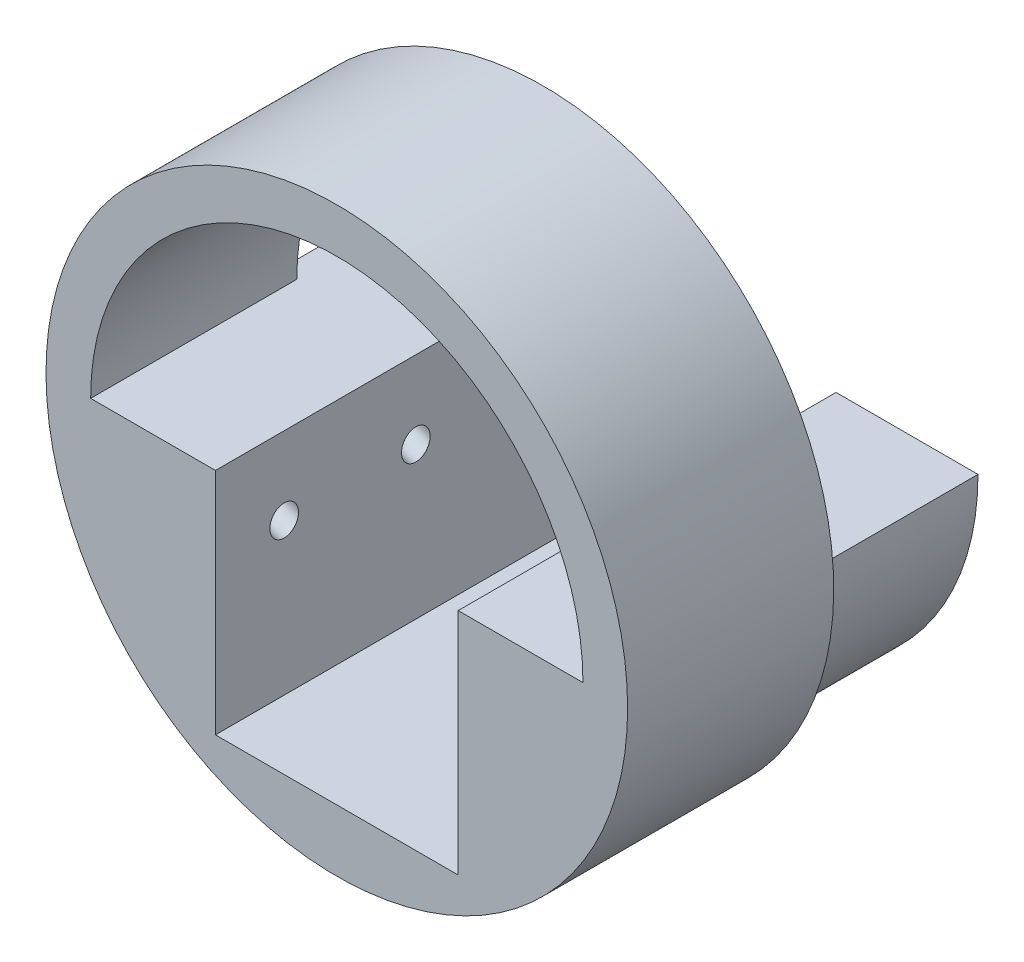
from build123d import *

# Parameters (mm, degrees)
SKETCH1_R                       = 25.4
BOSS_EXTRUDE1_DEPTH             = 33
CUT_EXTRUDE1_DEPTH              = 34
SKETCH3_R                       = 25.4
SKETCH3_R_2                     = 23
CUT_EXTRUDE2_DEPTH              = 15
M3X0_5_TAPPED_HOLE1_D           = 2.5
M3X0_5_TAPPED_HOLE1_DEPTH       = 25
M3X0_5_TAPPED_HOLE1_CSINK_D     = 3.05
M3X0_5_TAPPED_HOLE1_CSINK_ANGLE = 90
M3X0_5_TAPPED_HOLE1_TIP         = 0.751075774
SKETCH6_W                       = 55.513598287
SKETCH6_H                       = 26.495126455
CUT_EXTRUDE3_DEPTH              = 15


with BuildPart() as part:
    # Sketch1 → Boss-Extrude1 (new body)
    with BuildSketch(Plane.XY):
        Circle(SKETCH1_R)
    extrude(amount=BOSS_EXTRUDE1_DEPTH)

    # Sketch2 → Cut-Extrude1 (cut, through all)
    with BuildSketch(Plane.XY.offset(33)):
        with BuildLine():
            Line((-21.5, 0), (-10.6, 0))
            Line((-10.6, 0), (-10.6, -20))
            Line((-10.6, -20), (10.6, -20))
            Line((10.6, -20), (10.6, 0))
            Line((10.6, 0), (21.5, 0))
            ThreePointArc((21.5, 0), (0, 21.5), (-21.5, 0))
        make_face()
    extrude(amount=-CUT_EXTRUDE1_DEPTH, mode=Mode.SUBTRACT)

    # Sketch3 → Cut-Extrude2 (cut)
    with BuildSketch(Plane(origin=(0, 0, 0), x_dir=(-1, 0, 0), z_dir=(0, 0, -1))):
        Circle(SKETCH3_R)
        Circle(SKETCH3_R_2, mode=Mode.SUBTRACT)
    extrude(amount=-CUT_EXTRUDE2_DEPTH, mode=Mode.SUBTRACT)

    # M3x0.5 Tapped Hole1
    with Locations(Plane(origin=(-23.868192568, 8.68731164, 0), x_dir=(0, 0, -1), z_dir=(-0.939692621, 0.342020143, 0))):
        with Locations((-27, 10), (-15.5, 10), (-6, 10)):
            CounterSinkHole(M3X0_5_TAPPED_HOLE1_D / 2, M3X0_5_TAPPED_HOLE1_CSINK_D / 2, depth=M3X0_5_TAPPED_HOLE1_DEPTH, counter_sink_angle=M3X0_5_TAPPED_HOLE1_CSINK_ANGLE)
            with Locations((0, 0, -(M3X0_5_TAPPED_HOLE1_DEPTH + M3X0_5_TAPPED_HOLE1_TIP / 2))):  # 118° drill point
                Cone(0, M3X0_5_TAPPED_HOLE1_D / 2, M3X0_5_TAPPED_HOLE1_TIP, mode=Mode.SUBTRACT)

    # Sketch6 → Cut-Extrude3 (cut)
    with BuildSketch(Plane(origin=(0, 0, 0), x_dir=(-1, 0, 0), z_dir=(0, 0, -1))):
        with Locations((1.479202462, 13.247563228)):
            Rectangle(SKETCH6_W, SKETCH6_H)
    extrude(amount=-CUT_EXTRUDE3_DEPTH, mode=Mode.SUBTRACT)


solid = part.part
